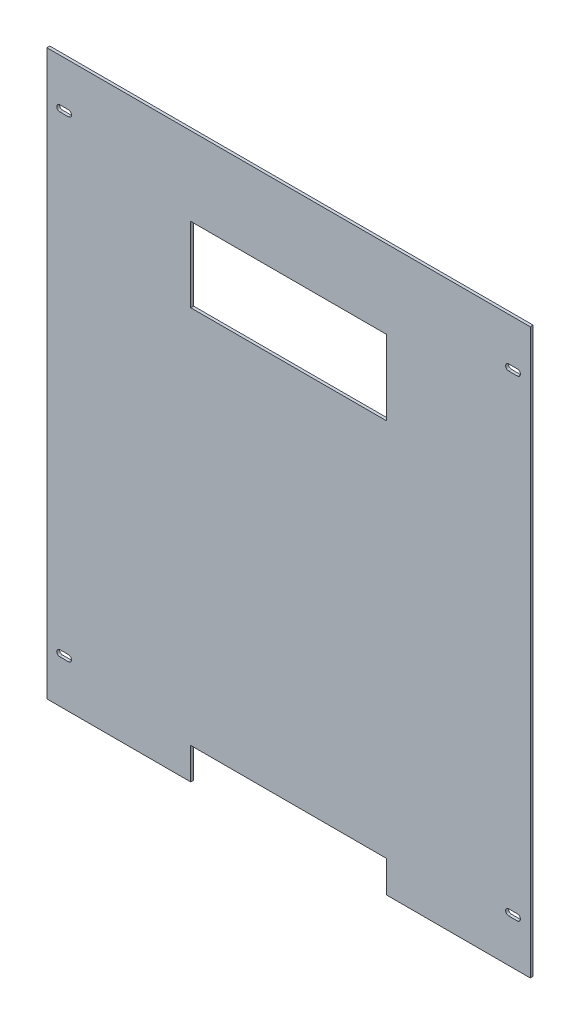
from build123d import *

# Parameters (mm, degrees)
SKETCH1_W            = 533.4
SKETCH1_H            = 622.3
BOSS_EXTRUDE1_DEPTH  = 3.175
CUT_EXTRUDE1_DEPTH   = 4.175
LPATTERN1_COUNT      = 2
LPATTERN1_PITCH      = 520.7
LPATTERN1_COUNT_DIR2 = 2
LPATTERN1_PITCH_DIR2 = 495.3
SKETCH5_W            = 215.9
SKETCH5_H            = 82.55
CUT_EXTRUDE3_DEPTH   = 4.175
SKETCH6_W            = 215.9
SKETCH6_H            = 34.925
CUT_EXTRUDE4_DEPTH   = 4.175


with BuildPart() as part:
    # Sketch1 → Boss-Extrude1 (new body)
    with BuildSketch(Plane.XY):
        with Locations((266.7, 311.15)):
            Rectangle(SKETCH1_W, SKETCH1_H)
    extrude(amount=BOSS_EXTRUDE1_DEPTH)

    # Sketch2 → Cut-Extrude1 (cut, through all)
    with BuildSketch(Plane.XY.offset(3.175)):
        with BuildLine():
            Line((14.2875, 574.8782), (23.8125, 574.8782))
            ThreePointArc((23.8125, 574.8782), (27.1907, 571.5), (23.8125, 568.1218))
            Line((23.8125, 568.1218), (14.2875, 568.1218))
            ThreePointArc((14.2875, 568.1218), (10.9093, 571.5), (14.2875, 574.8782))
        make_face()
    cut_extrude1 = extrude(amount=-CUT_EXTRUDE1_DEPTH, mode=Mode.SUBTRACT)

    # LPattern1: Cut-Extrude1 2 × 2
    with Locations(*[(j * LPATTERN1_PITCH_DIR2, -i * LPATTERN1_PITCH, 0) for i in range(LPATTERN1_COUNT) for j in range(LPATTERN1_COUNT_DIR2) if (i, j) != (0, 0)]):
        add(cut_extrude1, mode=Mode.SUBTRACT)

    # Sketch5 → Cut-Extrude3 (cut, through all)
    with BuildSketch(Plane(origin=(0, 0, 0), x_dir=(-1, 0, 0), z_dir=(0, 0, -1))):
        with Locations((-266.7, 494.422045059)):
            Rectangle(SKETCH5_W, SKETCH5_H)
    extrude(amount=-CUT_EXTRUDE3_DEPTH, mode=Mode.SUBTRACT)

    # Sketch6 → Cut-Extrude4 (cut, through all)
    with BuildSketch(Plane(origin=(0, 0, 0), x_dir=(-1, 0, 0), z_dir=(0, 0, -1))):
        with Locations((-266.7, 17.4625)):
            Rectangle(SKETCH6_W, SKETCH6_H)
    extrude(amount=-CUT_EXTRUDE4_DEPTH, mode=Mode.SUBTRACT)


solid = part.part
